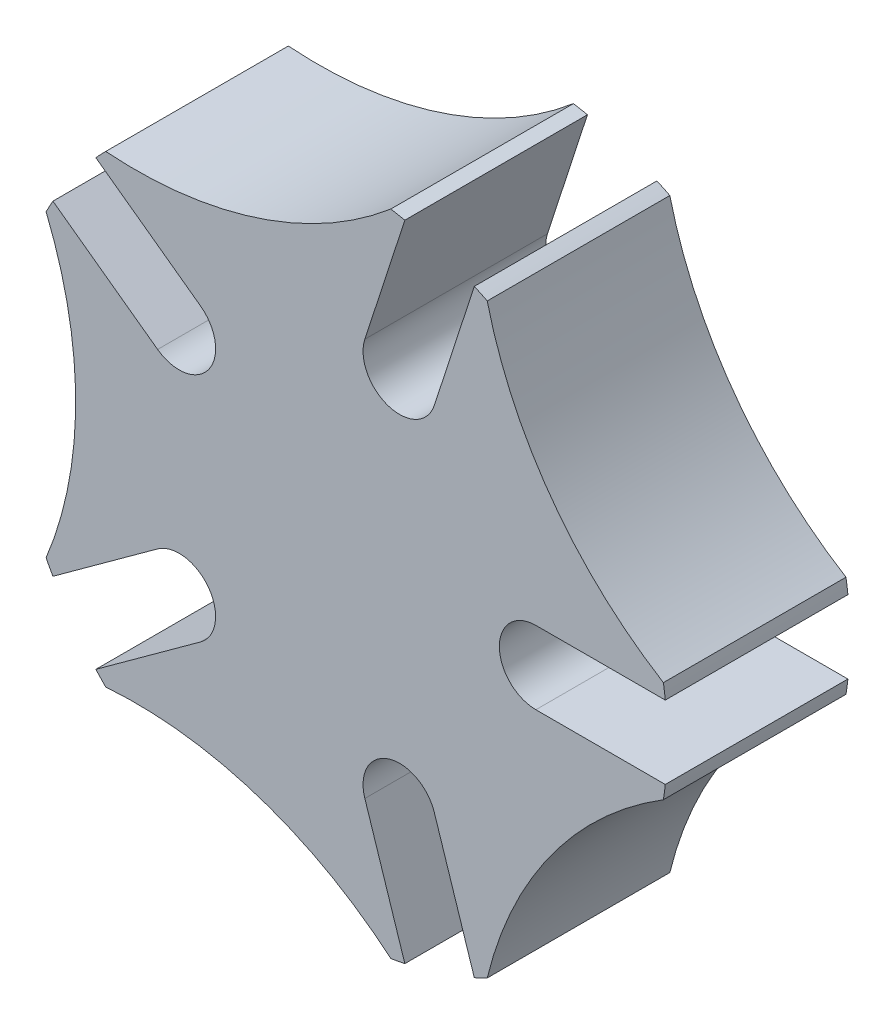
from build123d import *

# Parameters (mm, degrees)
SALIENTE_EXTRUIR1_DEPTH = 5


with BuildPart() as part:
    # Croquis1 → Saliente-Extruir1 (new body)
    with BuildSketch(Plane.XY):
        with BuildLine():
            ThreePointArc((-3.559674775, 2.58625511), (-4.212257305, 2.186352022), (-4.956477022, 2.365023368))
            Line((-4.956477022, 2.365023368), (-7.823412697, 4.447974061))
            ThreePointArc((-7.823412697, 4.447974061), (-7.918450076, 4.276494812), (-8.00972943, 4.102985978))
            ThreePointArc((-8.00972943, 4.102985978), (-7.404365943, 2.091061673), (-7.2, 0))
            ThreePointArc((-7.2, 0), (-7.404365943, -2.091061673), (-8.00972943, -4.102985978))
            ThreePointArc((-8.00972943, -4.102985978), (-7.918450076, -4.276494812), (-7.823412697, -4.447974061))
            Line((-7.823412697, -4.447974061), (-4.956477022, -2.365023368))
            ThreePointArc((-4.956477022, -2.365023368), (-3.559674775, -2.58625511), (-3.780906517, -3.983057357))
            Line((-3.780906517, -3.983057357), (-6.647842193, -6.06600805))
            ThreePointArc((-6.647842193, -6.06600805), (-6.514123901, -6.20938397), (-6.377314065, -6.349812973))
            ThreePointArc((-6.377314065, -6.349812973), (-2.224922359, -6.847606917), (1.427029037, -8.885597763))
            ThreePointArc((1.427029037, -8.885597763), (1.620252616, -8.852403117), (1.812707238, -8.815007201))
            Line((1.812707238, -8.815007201), (0.717635253, -5.444722182))
            ThreePointArc((0.717635253, -5.444722182), (1.359674775, -4.184648672), (2.619748286, -4.826688194))
            Line((2.619748286, -4.826688194), (3.71482027, -8.196973212))
            ThreePointArc((3.71482027, -8.196973212), (3.892500098, -8.114105155), (4.068332581, -8.027386218))
            ThreePointArc((4.068332581, -8.027386218), (5.824922359, -4.232053817), (8.891681878, -1.38861545))
            ThreePointArc((8.891681878, -1.38861545), (8.919821263, -1.194591196), (8.943727382, -1))
            Line((8.943727382, -1), (5.4, -1))
            ThreePointArc((5.4, -1), (4.4, 0), (5.4, 1))
            Line((5.4, 1), (8.943727382, 1))
            ThreePointArc((8.943727382, 1), (8.919821263, 1.194591196), (8.891681878, 1.38861545))
            ThreePointArc((8.891681878, 1.38861545), (5.824922359, 4.232053817), (4.068332581, 8.027386218))
            ThreePointArc((4.068332581, 8.027386218), (3.892500098, 8.114105155), (3.71482027, 8.196973212))
            Line((3.71482027, 8.196973212), (2.619748286, 4.826688194))
            ThreePointArc((2.619748286, 4.826688194), (1.359674775, 4.184648672), (0.717635253, 5.444722182))
            Line((0.717635253, 5.444722182), (1.812707238, 8.815007201))
            ThreePointArc((1.812707238, 8.815007201), (1.620252616, 8.852403117), (1.427029037, 8.885597763))
            ThreePointArc((1.427029037, 8.885597763), (-2.224922359, 6.847606917), (-6.377314065, 6.349812973))
            ThreePointArc((-6.377314065, 6.349812973), (-6.514123901, 6.20938397), (-6.647842193, 6.06600805))
            Line((-6.647842193, 6.06600805), (-3.780906517, 3.983057357))
            ThreePointArc((-3.780906517, 3.983057357), (-3.381003429, 3.330474827), (-3.559674775, 2.58625511))
        make_face()
    extrude(amount=SALIENTE_EXTRUIR1_DEPTH)


solid = part.part
